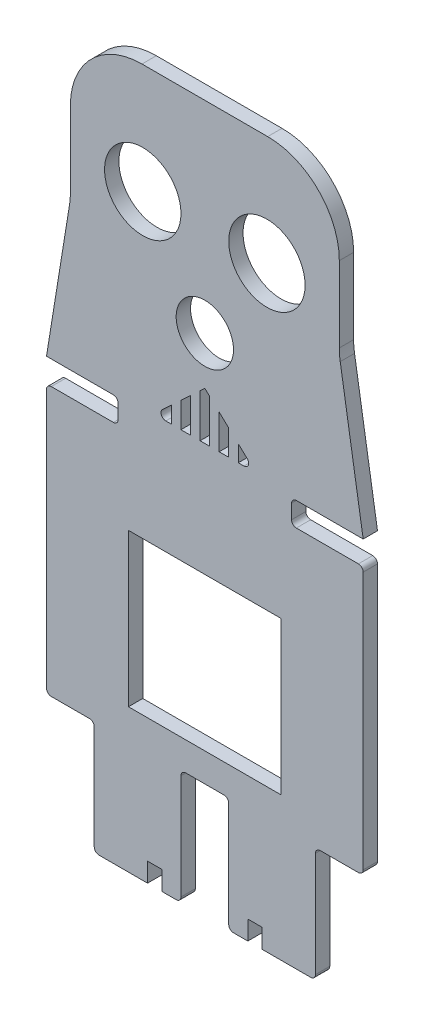
from build123d import *

# Parameters (mm, degrees)
MODEL_R                 = 8
MODEL_R_2               = 6
SALIENTE_EXTRUIR1_DEPTH = 3


with BuildPart() as part:
    # Model → Saliente-Extruir1 (new body)
    with BuildSketch(Plane.XY):
        with BuildLine():
            Line((30.519021416, 15.672169472), (30.519021416, -38.327830528))
            ThreePointArc((30.519021416, -38.327830528), (30.226128197, -39.034937309), (29.519021416, -39.327830528))
            Line((29.519021416, -39.327830528), (21.519021416, -39.327830528))
            ThreePointArc((21.519021416, -39.327830528), (20.811914634, -39.620723747), (20.519021416, -40.327830528))
            Line((20.519021416, -40.327830528), (20.519021416, -62.327830528))
            ThreePointArc((20.519021416, -62.327830528), (20.226128197, -63.034937309), (19.519021416, -63.327830528))
            Line((19.519021416, -63.327830528), (9.355410048, -63.327830528))
            Line((9.355410048, -63.327830528), (9.355410048, -59.327830528))
            Line((9.355410048, -59.327830528), (6.355410048, -59.327830528))
            Line((6.355410048, -59.327830528), (6.355410048, -63.327830528))
            Line((6.355410048, -63.327830528), (3.355410048, -63.327830528))
            ThreePointArc((3.355410048, -63.327830528), (2.648303267, -63.034937309), (2.355410048, -62.327830528))
            Line((2.355410048, -62.327830528), (2.355410048, -40.327830528))
            ThreePointArc((2.355410048, -40.327830528), (2.062516829, -39.620723747), (1.355410048, -39.327830528))
            Line((1.355410048, -39.327830528), (-6.644589952, -39.327830528))
            ThreePointArc((-6.644589952, -39.327830528), (-7.351696733, -39.620723747), (-7.644589952, -40.327830528))
            Line((-7.644589952, -40.327830528), (-7.644589952, -62.327830528))
            ThreePointArc((-7.644589952, -62.327830528), (-7.937483171, -63.034937309), (-8.644589952, -63.327830528))
            Line((-8.644589952, -63.327830528), (-11.644589952, -63.327830528))
            Line((-11.644589952, -63.327830528), (-11.644589952, -59.327830528))
            Line((-11.644589952, -59.327830528), (-14.644589952, -59.327830528))
            Line((-14.644589952, -59.327830528), (-14.644589952, -63.327830528))
            Line((-14.644589952, -63.327830528), (-24.80820132, -63.327830528))
            ThreePointArc((-24.80820132, -63.327830528), (-25.515308101, -63.034937309), (-25.80820132, -62.327830528))
            Line((-25.80820132, -62.327830528), (-25.80820132, -40.549556443))
            ThreePointArc((-25.80820132, -40.549556443), (-26.101094538, -39.842449662), (-26.80820132, -39.549556443))
            Line((-26.80820132, -39.549556443), (-34.80820132, -39.549556443))
            ThreePointArc((-34.80820132, -39.549556443), (-35.515308101, -39.256663224), (-35.80820132, -38.549556443))
            Line((-35.80820132, -38.549556443), (-35.80820132, 8.978477483))
            Line((-35.80820132, 8.978477483), (-35.80820132, 15.672169472))
            ThreePointArc((-35.80820132, 15.672169472), (-35.515308101, 16.379276253), (-34.80820132, 16.672169472))
            Line((-34.80820132, 16.672169472), (-21.80820132, 16.672169472))
            ThreePointArc((-21.80820132, 16.672169472), (-21.101094538, 16.965062691), (-20.80820132, 17.672169472))
            Line((-20.80820132, 17.672169472), (-20.80820132, 20.672169472))
            ThreePointArc((-20.80820132, 20.672169472), (-21.101094538, 21.379276253), (-21.80820132, 21.672169472))
            Line((-21.80820132, 21.672169472), (-35.80820132, 21.672169472))
            Line((-35.80820132, 21.672169472), (-31.000008461, 51.449360761))
            ThreePointArc((-31.000008461, 51.449360761), (-30.856229997, 52.641077199), (-30.80820132, 53.840474364))
            Line((-30.80820132, 53.840474364), (-30.80820132, 69.672169472))
            ThreePointArc((-30.80820132, 69.672169472), (-26.414803037, 80.27877119), (-15.80820132, 84.672169472))
            Line((-15.80820132, 84.672169472), (10.519021416, 84.672169472))
            ThreePointArc((10.519021416, 84.672169472), (21.125623133, 80.27877119), (25.519021416, 69.672169472))
            Line((25.519021416, 69.672169472), (25.519021416, 62.471272593))
            Line((25.519021416, 62.471272593), (25.519021416, 53.840474364))
            ThreePointArc((25.519021416, 53.840474364), (25.567050093, 52.641077199), (25.710828557, 51.449360761))
            Line((25.710828557, 51.449360761), (30.519021416, 21.672169472))
            Line((30.519021416, 21.672169472), (16.519021416, 21.672169472))
            ThreePointArc((16.519021416, 21.672169472), (15.811914634, 21.379276253), (15.519021416, 20.672169472))
            Line((15.519021416, 20.672169472), (15.519021416, 17.672169472))
            ThreePointArc((15.519021416, 17.672169472), (15.811914634, 16.965062691), (16.519021416, 16.672169472))
            Line((16.519021416, 16.672169472), (29.519021416, 16.672169472))
            ThreePointArc((29.519021416, 16.672169472), (30.226128197, 16.379276253), (30.519021416, 15.672169472))
        make_face()
        with Locations((-15.644589952, 61.620749462)):
            Circle(MODEL_R, mode=Mode.SUBTRACT)
        with Locations((10.355410048, 61.620749462)):
            Circle(MODEL_R, mode=Mode.SUBTRACT)
        with Locations((-2.644589952, 42.420749462)):
            Circle(MODEL_R_2, mode=Mode.SUBTRACT)
        with BuildLine():
            Line((4.355410048, 22.420749462), (5.535659362, 22.420749462))
            ThreePointArc((5.535659362, 22.420749462), (6.488784367, 23.118172652), (6.112446409, 24.23764401))
            Line((6.112446409, 24.23764401), (4.355410048, 25.879525262))
            Line((4.355410048, 25.879525262), (4.355410048, 22.420749462))
        make_face(mode=Mode.SUBTRACT)
        Polygon((2.355410048, 22.420749462), (0.355410048, 22.420749462), (0.355410048, 29.617367662), (2.355410048, 27.748446462), align=None, mode=Mode.SUBTRACT)
        Polygon((-3.644589952, 31.486288862), (-2.644589952, 32.420749462), (-1.644589952, 31.486288862), (-1.644589952, 22.420749462), (-3.644589952, 22.420749462), align=None, mode=Mode.SUBTRACT)
        Polygon((-5.644589952, 22.420749462), (-7.644589952, 22.420749462), (-7.644589952, 27.748446462), (-5.644589952, 29.617367662), align=None, mode=Mode.SUBTRACT)
        with BuildLine():
            Line((-9.644589952, 22.420749462), (-10.824839266, 22.420749462))
            ThreePointArc((-10.824839266, 22.420749462), (-11.777964271, 23.118172652), (-11.401626313, 24.23764401))
            Line((-11.401626313, 24.23764401), (-9.644589952, 25.879525262))
            Line((-9.644589952, 25.879525262), (-9.644589952, 22.420749462))
        make_face(mode=Mode.SUBTRACT)
        Polygon((13.355410048, -33.327830528), (-18.644589952, -33.327830528), (-18.644589952, -1.327830528), (-2.144589952, -1.327830528), (13.355410048, -1.327830528), align=None, mode=Mode.SUBTRACT)
    extrude(amount=SALIENTE_EXTRUIR1_DEPTH)


solid = part.part
